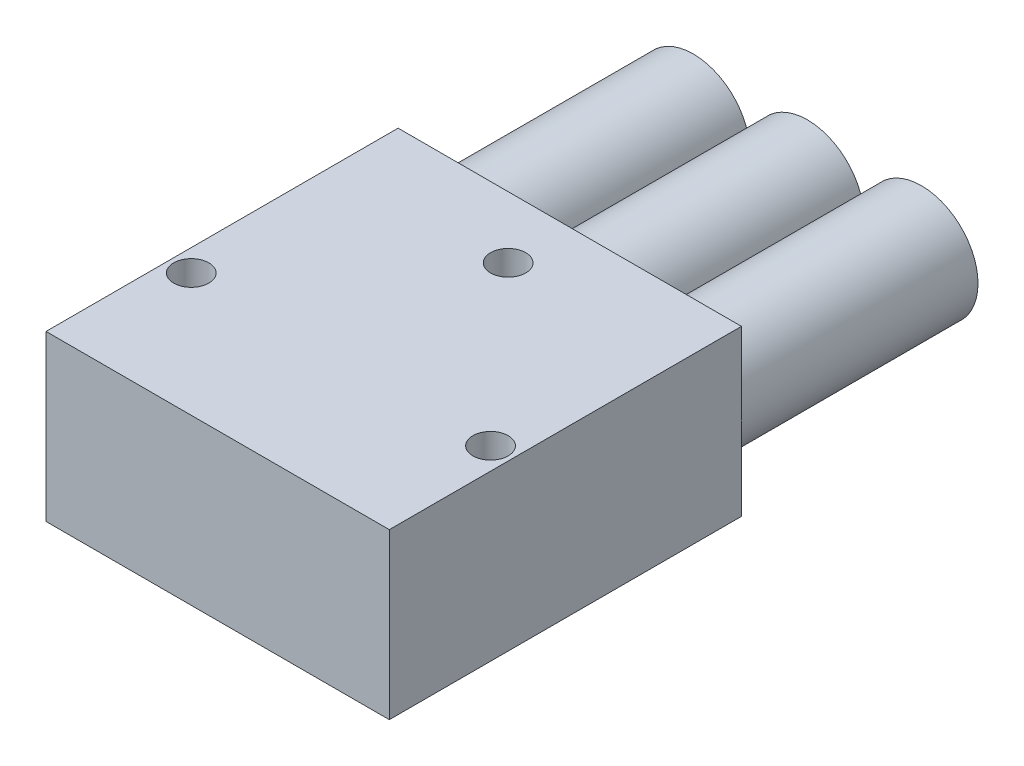
from build123d import *

# Parameters (mm, degrees)
SKETCH1_W           = 39
SKETCH1_H           = 40
BOSS_EXTRUDE1_DEPTH = 18.7
SKETCH2_R           = 2
CUT_EXTRUDE1_DEPTH  = 3
SKETCH3_R           = 6.417093559
BOSS_EXTRUDE4_DEPTH = 27


with BuildPart() as part:
    # Sketch1 → Boss-Extrude1 (new body)
    with BuildSketch(Plane(origin=(0, 0, 0), x_dir=(1, 0, 0), z_dir=(0, 1, 0))):
        with Locations((19.5, 20)):
            Rectangle(SKETCH1_W, SKETCH1_H)
    extrude(amount=BOSS_EXTRUDE1_DEPTH)

    # Sketch2 → Cut-Extrude1 (cut)
    with BuildSketch(Plane(origin=(0, 18.7, 0), x_dir=(1, 0, 0), z_dir=(0, 1, 0))):
        with Locations((2.5, 14)):
            Circle(SKETCH2_R)
        with Locations((36.5, 14)):
            Circle(SKETCH2_R)
        with Locations((19.5, 33)):
            Circle(SKETCH2_R)
    extrude(amount=-CUT_EXTRUDE1_DEPTH, mode=Mode.SUBTRACT)

    # Sketch3 → Boss-Extrude4 (add)
    with BuildSketch(Plane(origin=(0, 0, -40), x_dir=(-1, 0, 0), z_dir=(0, 0, -1))):
        with Locations((-32.458546779, 9.35)):
            Circle(SKETCH3_R)
        with Locations((-19.5, 9.35)):
            Circle(SKETCH3_R)
        with Locations((-6.541453221, 9.35)):
            Circle(SKETCH3_R)
    extrude(amount=BOSS_EXTRUDE4_DEPTH)


solid = part.part
